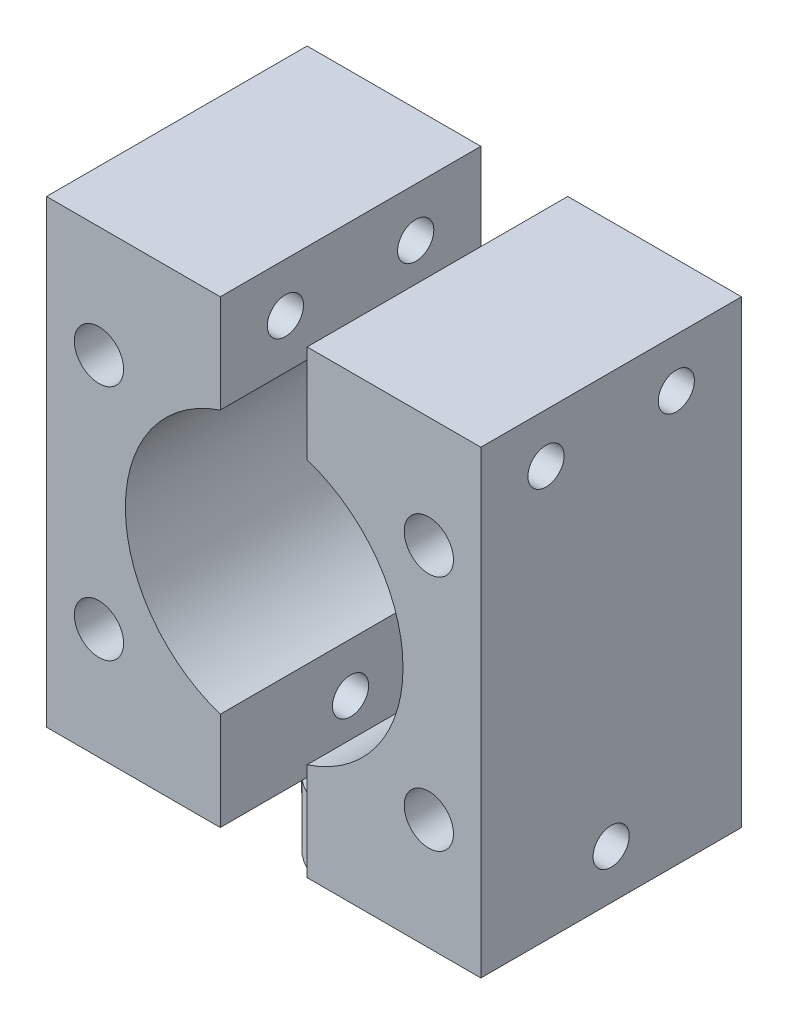
from build123d import *

# Parameters (mm, degrees)
SKETCH2_W                 = 12
SKETCH2_H                 = 18
EXTRUDE1_DEPTH            = 31.75
EXTRUDE1_2_DEPTH          = 31.75
EXTRUDE2_DEPTH            = 4.5
SKETCH4_R                 = 9.5885
EXTRUDE3_DEPTH            = 17
M3_CLEARANCE_HOLE1_D      = 3.4
M3X0_5_TAPPED_HOLE1_D     = 2.5
M2X0_4_TAPPED_HOLE2_D     = 1.6
M2X0_4_TAPPED_HOLE2_DEPTH = 6
M2X0_4_TAPPED_HOLE2_TIP   = 0.480688495


with BuildPart() as part:
    # Sketch2 → Extrude1 (new body)
    with BuildSketch(Plane(origin=(0, 4.5, 0), x_dir=(-1, 0, 0), z_dir=(0, 1, 0))):
        with Locations((9, 0.343878918)):
            Rectangle(SKETCH2_W, SKETCH2_H)
    extrude(amount=EXTRUDE1_DEPTH)



with BuildPart() as body_2:
    # Sketch2 → Extrude1 2 (new body)
    with BuildSketch(Plane(origin=(0, 4.5, 0), x_dir=(-1, 0, 0), z_dir=(0, 1, 0))):
        with Locations((-9, 0.343878918)):
            Rectangle(SKETCH2_W, SKETCH2_H)
    extrude(amount=EXTRUDE1_2_DEPTH)


with BuildPart() as part_1:
    add(part.part)

    add(body_2.part)  # Extrude2 merges body 2
    # Sketch1 → Extrude2 (add)
    with BuildSketch(Plane(origin=(0, 0, 0), x_dir=(1, 0, 0), z_dir=(0, 1, 0))):
        with BuildLine():
            ThreePointArc((4.75, 0), (3.852758752, 2.778263846), (1.5, 4.506939094))
            Line((1.5, 4.506939094), (1.5, -4.506939094))
            ThreePointArc((1.5, -4.506939094), (3.852758752, -2.778263846), (4.75, 0))
        make_face()
        with BuildLine():
            Line((-1.5, -4.506939094), (-1.5, 4.506939094))
            ThreePointArc((-1.5, 4.506939094), (-4.75, 0), (-1.5, -4.506939094))
        make_face()
    extrude(amount=EXTRUDE2_DEPTH)

    # Sketch4 → Extrude3 (cut)
    with BuildSketch(Plane.XY.offset(9.343878918)):
        with Locations((0.033766691, 20.375)):
            Circle(SKETCH4_R)
    extrude(amount=-EXTRUDE3_DEPTH, mode=Mode.SUBTRACT)

    # M3 Clearance Hole1 (through all)
    with Locations(Plane(origin=(-11.377218639, 28.569859147, 9.343878918), x_dir=(1, 0, 0), z_dir=(0, 0, 1))):
        with Locations((0, 0), (0, -16.389718294), (22.782225349, -16.398024537), (22.782225349, 0.008306243)):
            Hole(M3_CLEARANCE_HOLE1_D / 2)

    # M3x0.5 Tapped Hole1 (through all)
    with Locations(Plane(origin=(15, 32.871578641, 4.843878918), x_dir=(0, 0, 1), z_dir=(1, 0, 0))):
        with Locations((0, 0), (-9, 0), (-4.5, 24.993157282)):
            Hole(M3X0_5_TAPPED_HOLE1_D / 2)

    # M2x0.4 Tapped Hole2
    with Locations(Plane(origin=(-6.495190528, 4.5, 3.75), x_dir=(0, 0, -1), z_dir=(0, -1, 0))):
        with Locations((0, 0), (0, 12.990381056)):
            Hole(M2X0_4_TAPPED_HOLE2_D / 2, depth=M2X0_4_TAPPED_HOLE2_DEPTH)
            with Locations((0, 0, -(M2X0_4_TAPPED_HOLE2_DEPTH + M2X0_4_TAPPED_HOLE2_TIP / 2))):  # 118° drill point
                Cone(0, M2X0_4_TAPPED_HOLE2_D / 2, M2X0_4_TAPPED_HOLE2_TIP, mode=Mode.SUBTRACT)


solid = part_1.part
